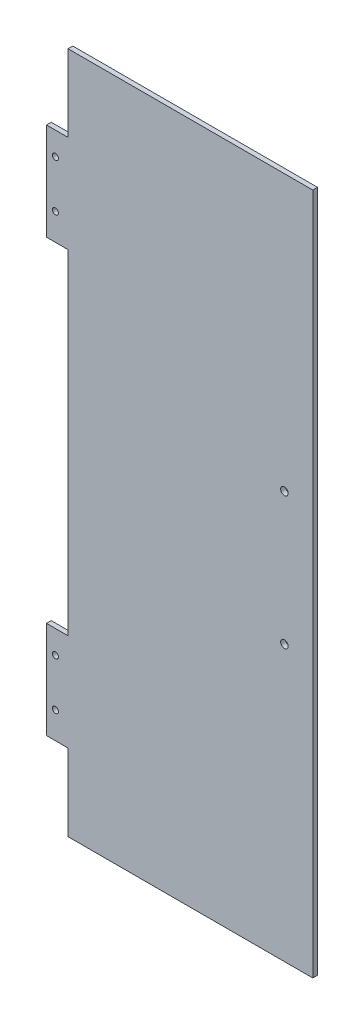
from build123d import *

# Parameters (mm, degrees)
SKETCH1_W           = 164.338
SKETCH1_H           = 458.216
SKETCH1_W_2         = 14.478
SKETCH1_H_2         = 65.278
BOSS_EXTRUDE3_DEPTH = 3.175
SKETCH2_R           = 2.032
CUT_EXTRUDE1_DEPTH  = 4.175
SKETCH4_R           = 2.54
CUT_EXTRUDE3_DEPTH  = 4.175


with BuildPart() as part:
    # Sketch1 → Boss-Extrude3 (new body)
    with BuildSketch(Plane.XY):
        with Locations((-82.169, 229.108)):
            Rectangle(SKETCH1_W, SKETCH1_H)
        with Locations((-171.577, 84.201)):
            Rectangle(SKETCH1_W_2, SKETCH1_H_2)
        with Locations((-171.577, 374.015)):
            Rectangle(SKETCH1_W_2, SKETCH1_H_2)
    extrude(amount=BOSS_EXTRUDE3_DEPTH)

    # Sketch2 → Cut-Extrude1 (cut, through all)
    with BuildSketch(Plane.XY.offset(3.175)):
        with Locations((-172.814936246, 69.493794716)):
            Circle(SKETCH2_R)
        with Locations((-172.814936246, 101.243794716)):
            Circle(SKETCH2_R)
        with Locations((-172.814936246, 391.16)):
            Circle(SKETCH2_R)
        with Locations((-172.814936246, 359.41)):
            Circle(SKETCH2_R)
    extrude(amount=-CUT_EXTRUDE1_DEPTH, mode=Mode.SUBTRACT)

    # Sketch4 → Cut-Extrude3 (cut, through all)
    with BuildSketch(Plane.XY.offset(3.175)):
        with Locations((-19.05, 184.635815808)):
            Circle(SKETCH4_R)
        with Locations((-19.05, 273.535815808)):
            Circle(SKETCH4_R)
    extrude(amount=-CUT_EXTRUDE3_DEPTH, mode=Mode.SUBTRACT)


solid = part.part
